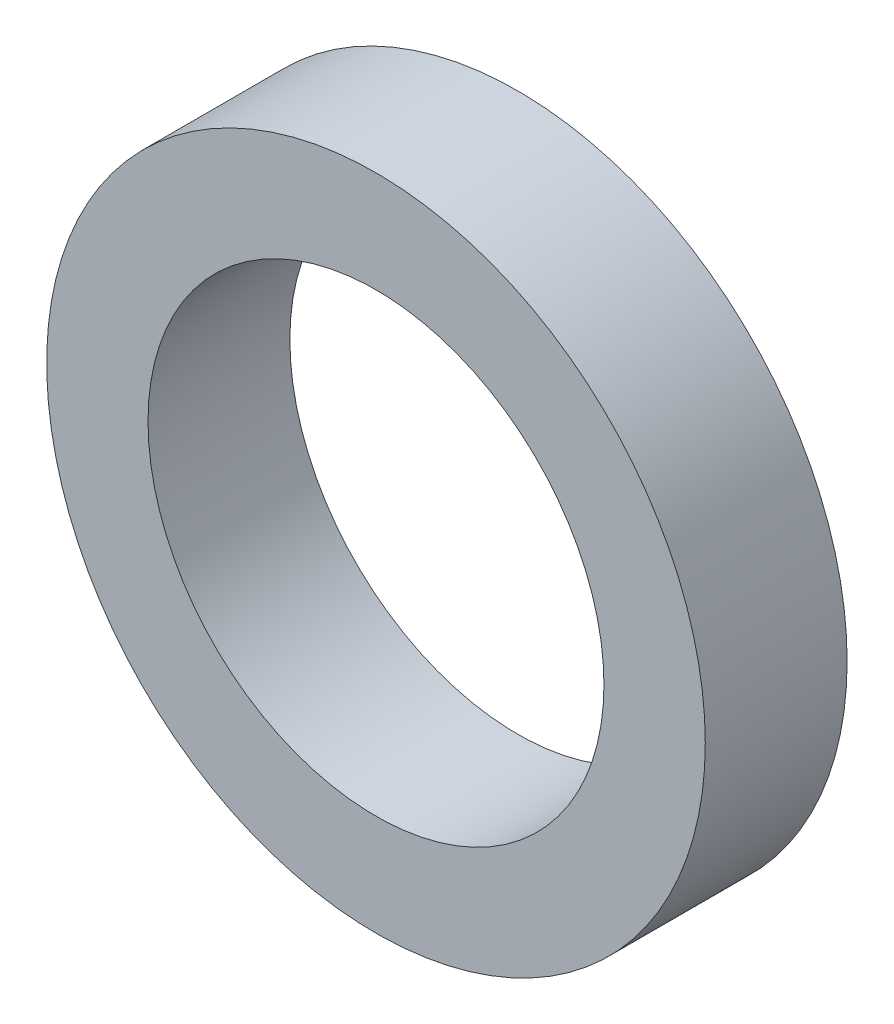
from build123d import *

# Parameters (mm, degrees)
SKETCH_1_R      = 32.5
SKETCH_1_R_2    = 22.5
EXTRUDE_1_DEPTH = 14


with BuildPart() as part:
    # 草图1 → 凸台-拉伸1 (new body)
    with BuildSketch(Plane.XY):
        with Locations((0.998101581, 0.499050791)):
            Circle(SKETCH_1_R)
        with Locations((0.998101581, 0.499050791)):
            Circle(SKETCH_1_R_2, mode=Mode.SUBTRACT)
    extrude(amount=EXTRUDE_1_DEPTH)


solid = part.part
